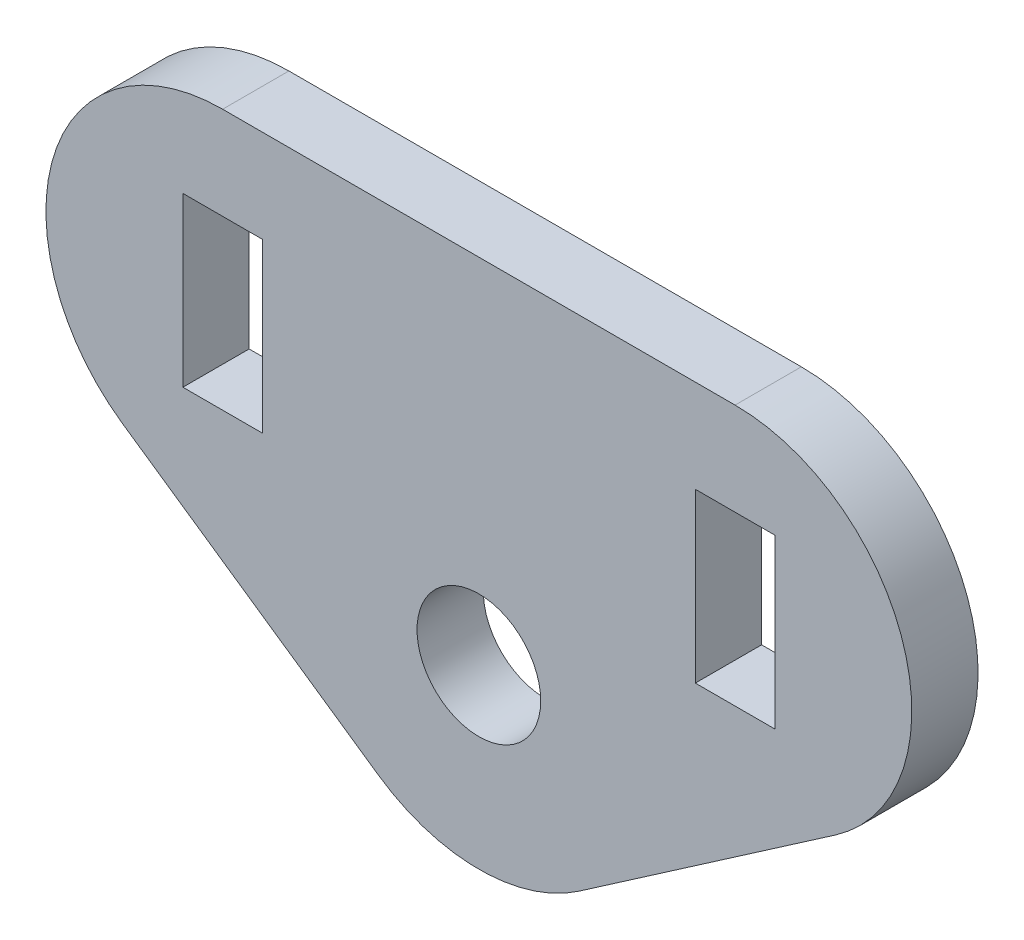
from build123d import *

# Parameters (mm, degrees)
SKETCH1_R           = 14
SKETCH1_W           = 18
SKETCH1_H           = 38
BOSS_EXTRUDE1_DEPTH = 15
FILLET1_R           = 40


with BuildPart() as part:
    # Sketch1 → Boss-Extrude1 (new body)
    with BuildSketch(Plane.XY):
        Polygon((186.455659815, 80), (-186.455659815, 80), (0, -48.590110217), align=None)
        Circle(SKETCH1_R, mode=Mode.SUBTRACT)
        with Locations((-58, 40)):
            Rectangle(SKETCH1_W, SKETCH1_H, mode=Mode.SUBTRACT)
        with Locations((58, 40)):
            Rectangle(SKETCH1_W, SKETCH1_H, mode=Mode.SUBTRACT)
    extrude(amount=BOSS_EXTRUDE1_DEPTH)

    # Fillet1
    fillet1_edges = [part.edges().sort_by_distance(p)[0] for p in [
        (0, -48.590110217, 7.5),
        (-186.455659815, 80, 7.5),
        (186.455659815, 80, 7.5),
    ]]
    fillet(fillet1_edges, radius=FILLET1_R)


solid = part.part
